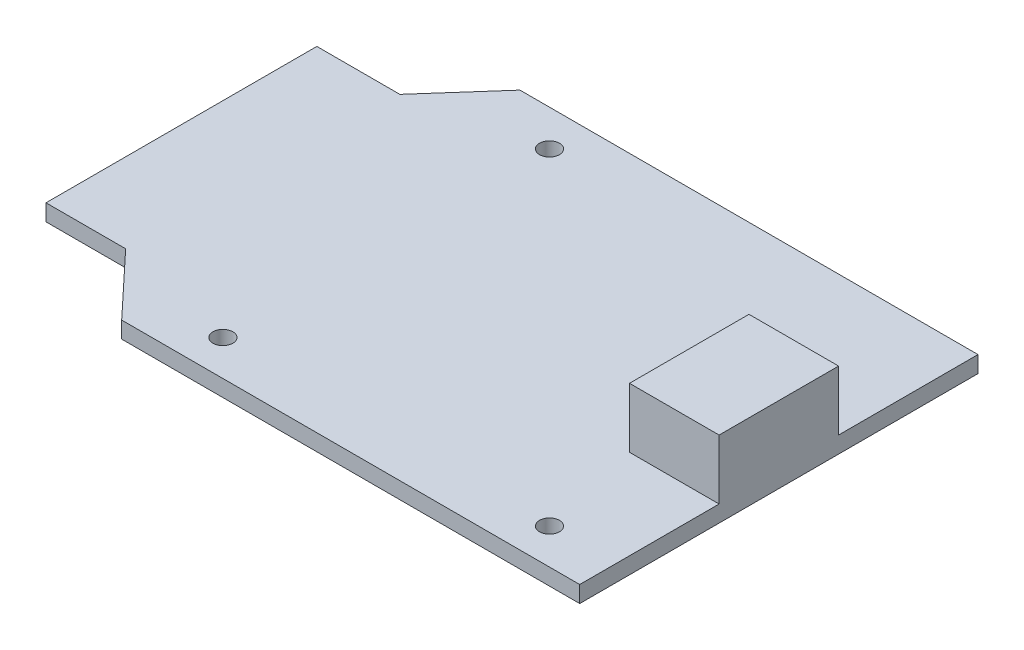
from build123d import *

# Parameters (mm, degrees)
SKETCH1_R           = 0.5
BOSS_EXTRUDE1_DEPTH = 0.83
SKETCH2_W           = 4.5
SKETCH2_H           = 6
BOSS_EXTRUDE2_DEPTH = 3


with BuildPart() as part:
    # Sketch1 → Boss-Extrude1 (new body)
    with BuildSketch(Plane(origin=(0, 0, 0), x_dir=(1, 0, 0), z_dir=(0, 1, 0))):
        Polygon((0, 0), (-2.83, -3.2), (-7, -3.2), (-7, -16.8), (-3, -16.8), (0, -20), (23, -20), (23, 0), align=None)
        with Locations((3.3, -18.217292277)):
            Circle(SKETCH1_R, mode=Mode.SUBTRACT)
        with Locations((3.3, -1.817292277)):
            Circle(SKETCH1_R, mode=Mode.SUBTRACT)
        with Locations((19.7, -18.217292277)):
            Circle(SKETCH1_R, mode=Mode.SUBTRACT)
    extrude(amount=BOSS_EXTRUDE1_DEPTH)

    # Sketch2 → Boss-Extrude2 (add)
    with BuildSketch(Plane(origin=(0, 0.83, 0), x_dir=(1, 0, 0), z_dir=(0, 1, 0))):
        with Locations((20.75, -10)):
            Rectangle(SKETCH2_W, SKETCH2_H)
    extrude(amount=BOSS_EXTRUDE2_DEPTH)


solid = part.part
